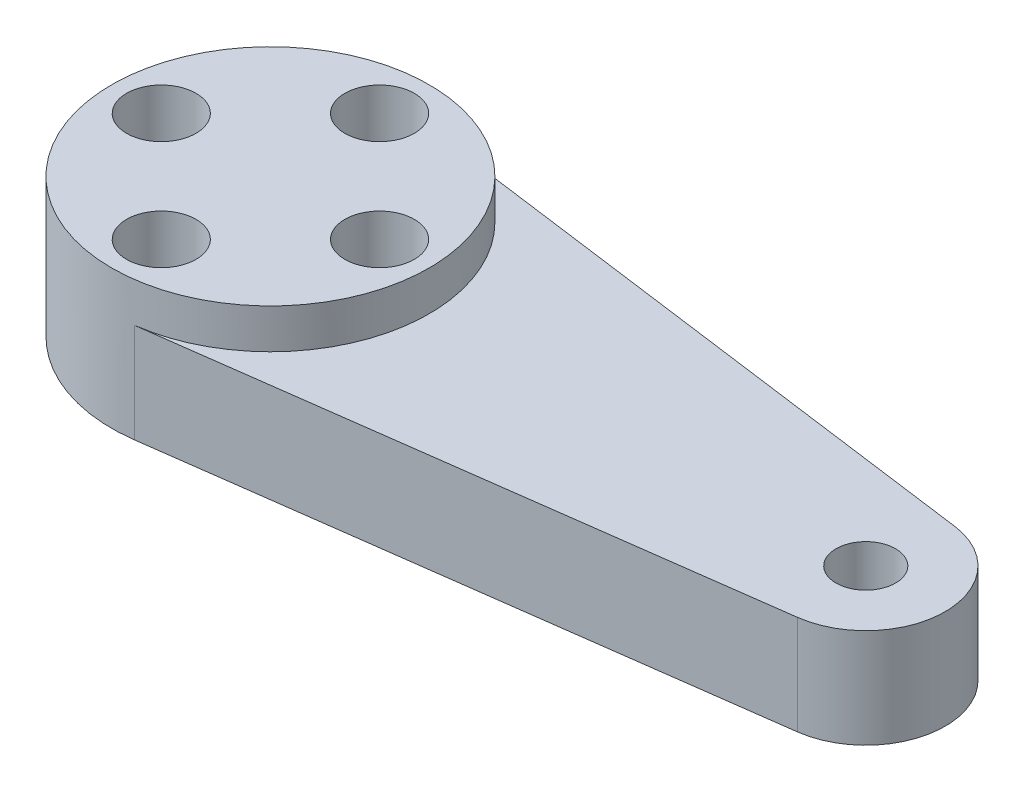
from build123d import *

# Parameters (mm, degrees)
SKETCH1_R           = 1.5
SKETCH1_R_2         = 1.75
BOSS_EXTRUDE1_DEPTH = 5
SKETCH2_R           = 8
SKETCH2_R_2         = 1.75
BOSS_EXTRUDE2_DEPTH = 2


with BuildPart() as part:
    # Sketch1 → Boss-Extrude1 (new body)
    with BuildSketch(Plane(origin=(0, 0, 0), x_dir=(1, 0, 0), z_dir=(0, 1, 0))):
        with BuildLine():
            Line((1.066666667, 7.928569999), (30.533333333, 3.964284999))
            ThreePointArc((30.533333333, 3.964284999), (34, 0), (30.533333333, -3.964284999))
            Line((30.533333333, -3.964284999), (1.066666667, -7.928569999))
            ThreePointArc((1.066666667, -7.928569999), (-8, 0), (1.066666667, 7.928569999))
        make_face()
        with Locations((30, 0)):
            Circle(SKETCH1_R, mode=Mode.SUBTRACT)
        with Locations((-5.5, 0)):
            Circle(SKETCH1_R_2, mode=Mode.SUBTRACT)
        with Locations((0, 5.5)):
            Circle(SKETCH1_R_2, mode=Mode.SUBTRACT)
        with Locations((5.5, 0)):
            Circle(SKETCH1_R_2, mode=Mode.SUBTRACT)
        with Locations((0, -5.5)):
            Circle(SKETCH1_R_2, mode=Mode.SUBTRACT)
    extrude(amount=BOSS_EXTRUDE1_DEPTH)

    # Sketch2 → Boss-Extrude2 (add)
    with BuildSketch(Plane(origin=(0, 5, 0), x_dir=(1, 0, 0), z_dir=(0, 1, 0))):
        Circle(SKETCH2_R)
        with Locations((-5.5, 0)):
            Circle(SKETCH2_R_2, mode=Mode.SUBTRACT)
        with Locations((0, -5.5)):
            Circle(SKETCH2_R_2, mode=Mode.SUBTRACT)
        with Locations((5.5, 0)):
            Circle(SKETCH2_R_2, mode=Mode.SUBTRACT)
        with Locations((0, 5.5)):
            Circle(SKETCH2_R_2, mode=Mode.SUBTRACT)
    extrude(amount=BOSS_EXTRUDE2_DEPTH)


solid = part.part
